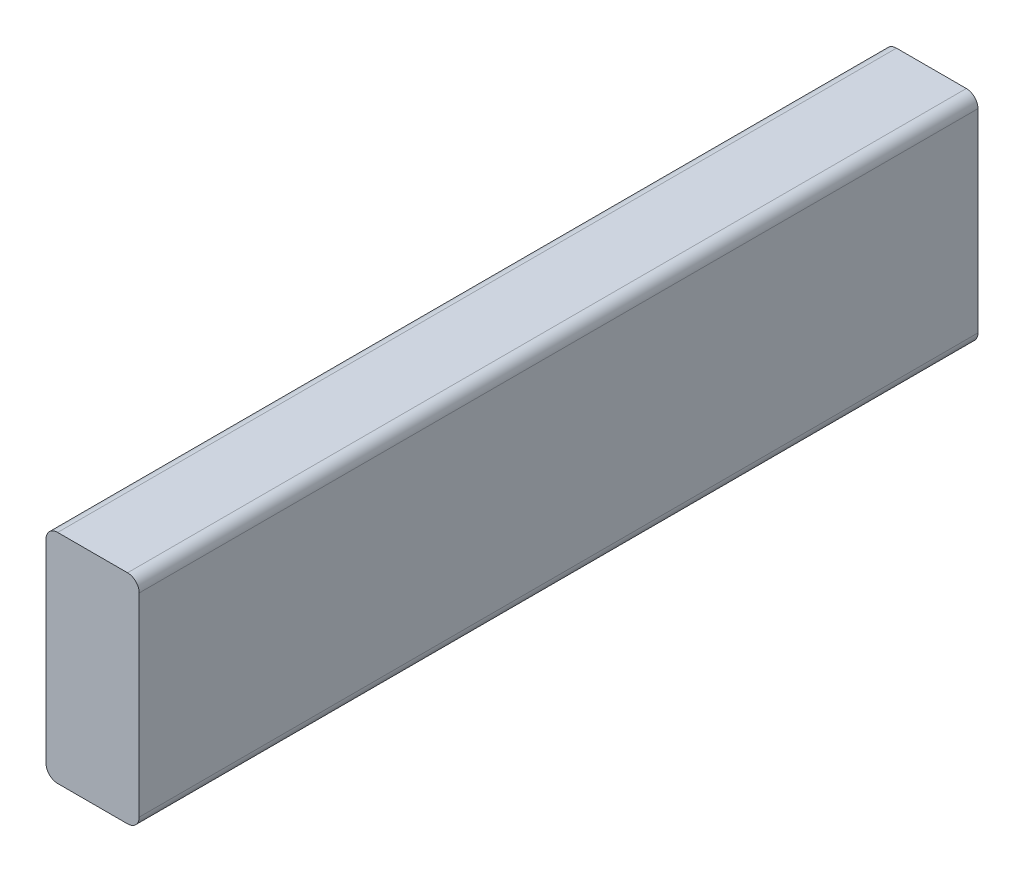
from build123d import *

# Parameters (mm, degrees)
SKETCH1_W           = 38.1
SKETCH1_H           = 88.9
BOSS_EXTRUDE1_DEPTH = 342.9
FILLET1_R           = 4.7625


with BuildPart() as part:
    # Sketch1 → Boss-Extrude1 (new body)
    with BuildSketch(Plane.XY):
        with Locations((242.53825, 1428.75)):
            Rectangle(SKETCH1_W, SKETCH1_H)
    extrude(amount=-BOSS_EXTRUDE1_DEPTH)

    # Fillet1
    fillet1_edges = [part.edges().sort_by_distance(p)[0] for p in [
        (261.58825, 1384.3, -171.45),
        (261.58825, 1473.2, -171.45),
        (223.48825, 1473.2, -171.45),
        (223.48825, 1384.3, -171.45),
    ]]
    fillet(fillet1_edges, radius=FILLET1_R)


solid = part.part
